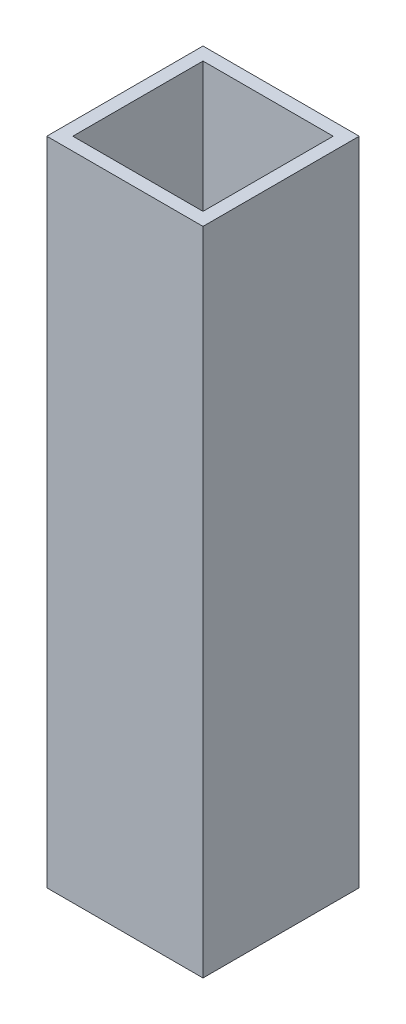
from build123d import *

# Parameters (mm, degrees)
SKETCH1_W           = 24
SKETCH1_H           = 100
BOSS_EXTRUDE1_DEPTH = 24
SKETCH2_W           = 20
SKETCH2_H           = 20
CUT_EXTRUDE1_DEPTH  = 200


with BuildPart() as part:
    # Sketch1 → Boss-Extrude1 (new body)
    with BuildSketch(Plane.XY):
        with Locations((-19.739130435, -0.217391304)):
            Rectangle(SKETCH1_W, SKETCH1_H)
    extrude(amount=-BOSS_EXTRUDE1_DEPTH)

    # Sketch2 → Cut-Extrude1 (cut)
    with BuildSketch(Plane(origin=(0, 49.782608696, 0), x_dir=(1, 0, 0), z_dir=(0, 1, 0))):
        with Locations((-19.739130435, 12)):
            Rectangle(SKETCH2_W, SKETCH2_H)
    extrude(amount=-CUT_EXTRUDE1_DEPTH, mode=Mode.SUBTRACT)


solid = part.part
